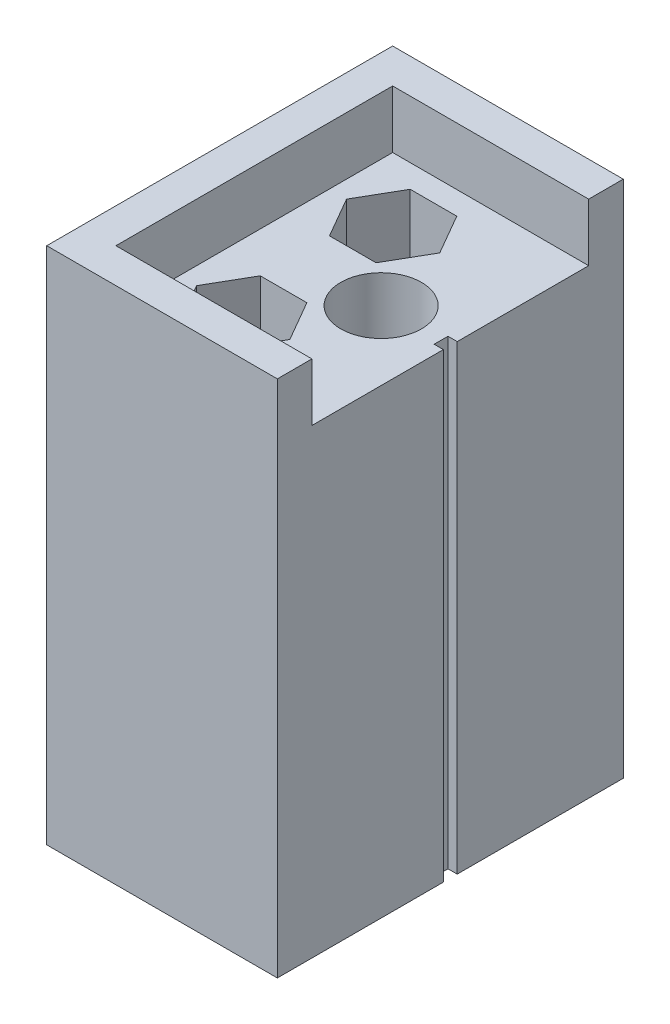
from build123d import *

# Parameters (mm, degrees)
SKETCH1_W           = 20
SKETCH1_H           = 30
BOSS_EXTRUDE1_DEPTH = 40
BOSS_EXTRUDE2_DEPTH = 5
SKETCH3_R           = 3.5
CUT_EXTRUDE1_DEPTH  = 41
SKETCH4_W           = 1.2
SKETCH4_H           = 40
CUT_EXTRUDE2_DEPTH  = 0.8


with BuildPart() as part:
    # Sketch1 → Boss-Extrude1 (new body)
    with BuildSketch(Plane(origin=(0, 0, 0), x_dir=(1, 0, 0), z_dir=(0, 1, 0))):
        with Locations((10, 15)):
            Rectangle(SKETCH1_W, SKETCH1_H)
    extrude(amount=BOSS_EXTRUDE1_DEPTH)

    # Sketch2 → Boss-Extrude2 (add)
    with BuildSketch(Plane(origin=(0, 40, 0), x_dir=(1, 0, 0), z_dir=(0, 1, 0))):
        Polygon((20, 0), (20, 3), (3, 3), (3, 27), (20, 27), (20, 30), (0, 30), (0, 0), align=None)
    extrude(amount=BOSS_EXTRUDE2_DEPTH)

    # Sketch3 → Cut-Extrude1 (cut, through all)
    with BuildSketch(Plane(origin=(0, 40, 0), x_dir=(1, 0, 0), z_dir=(0, 1, 0))):
        with Locations((14, 15)):
            Circle(SKETCH3_R)
        Polygon((12.582903769, 8.5), (10.562177826, 12), (6.520725942, 12), (4.5, 8.5), (6.520725942, 5), (10.562177826, 5), align=None)
        Polygon((12.582903769, 21.5), (10.562177826, 25), (6.520725942, 25), (4.5, 21.5), (6.520725942, 18), (10.562177826, 18), align=None)
    extrude(amount=-CUT_EXTRUDE1_DEPTH, mode=Mode.SUBTRACT)

    # Sketch4 → Cut-Extrude2 (cut)
    with BuildSketch(Plane(origin=(20, 0, 0), x_dir=(0, 0, -1), z_dir=(1, 0, 0))):
        with Locations((15, 20)):
            Rectangle(SKETCH4_W, SKETCH4_H)
    extrude(amount=-CUT_EXTRUDE2_DEPTH, mode=Mode.SUBTRACT)


solid = part.part
